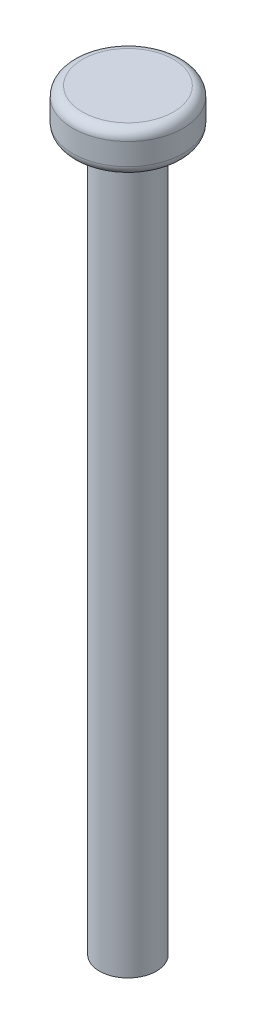
from build123d import *

# Parameters (mm, degrees)
SKETCH1_R           = 3
BOSS_EXTRUDE1_DEPTH = 75
SKETCH2_R           = 5.8
BOSS_EXTRUDE2_DEPTH = 4.3
FILLET1_R           = 1


with BuildPart() as part:
    # Sketch1 → Boss-Extrude1 (new body)
    with BuildSketch(Plane(origin=(0, 0, 0), x_dir=(1, 0, 0), z_dir=(0, 1, 0))):
        with Locations(Location((0, 0, 0), (0, 0, 270))):  # turned: the seam where the file's is
            Circle(SKETCH1_R)
    extrude(amount=BOSS_EXTRUDE1_DEPTH)

    # Sketch2 → Boss-Extrude2 (add)
    with BuildSketch(Plane(origin=(0, 75, 0), x_dir=(1, 0, 0), z_dir=(0, 1, 0))):
        with Locations(Location((0, 0, 0), (0, 0, 270))):  # turned: the seam where the file's is
            Circle(SKETCH2_R)
    extrude(amount=BOSS_EXTRUDE2_DEPTH)

    # Fillet1
    fillet1_edges = [part.edges().sort_by_distance(p)[0] for p in [
        (0, 75, -5.8),
        (0, 79.3, -5.8),
    ]]
    fillet(fillet1_edges, radius=FILLET1_R)


solid = part.part
